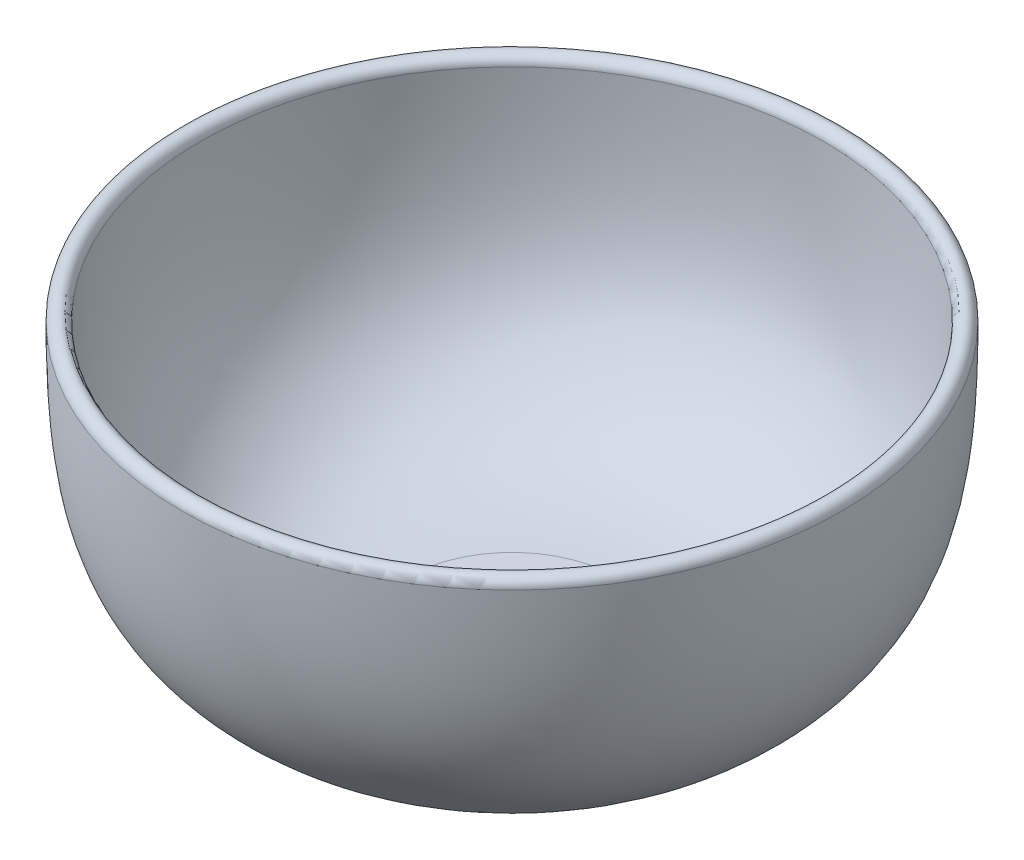
from build123d import *


with BuildPart() as part:
    # Sketch1 → Revolve1 (revolve)
    with BuildSketch(Plane.XY):
        with BuildLine():
            Line((0, -37.46), (-30, -37.46))
            add(Edge.make_bspline(
                [(-30, -37.46), (-30.860987655, -37.46), (-32.606384875, -37.436114905), (-35.907865784, -37.296406862), (-39.817777832, -36.956148055), (-44.141638766, -36.304452803), (-49.459131211, -35.139355309), (-55.314542104, -33.180371267), (-61.260272929, -30.180937219), (-66.306097048, -26.674863401), (-70.628017093, -22.778750971), (-74.360513918, -18.663243679), (-78.553686947, -12.892201761), (-81.720452029, -6.463840501), (-84.038098793, 1.011931752), (-85.383465168, 7.233798397), (-86.367922337, 14.152286295), (-86.914872267, 20.561245493), (-87.20606829, 26.11179732), (-87.355926733, 30.493774797), (-87.427627432, 34.341265749), (-87.455492262, 37.528398326), (-87.46, 39.181053667), (-87.46, 40)],
                knots=[0, 0, 0, 0, 0.015625, 0.03125, 0.0625, 0.09375, 0.125, 0.1875, 0.25, 0.3125, 0.375, 0.4375, 0.5, 0.625, 0.6875, 0.75, 0.8125, 0.875, 0.90625, 0.9375, 0.96875, 0.984375, 1, 1, 1, 1], degree=3))
            ThreePointArc((-87.46, 40), (-90, 42.54), (-92.54, 40))
            add(Edge.make_bspline(
                [(-30, -42.54), (-30.907962003, -42.54), (-32.746038976, -42.514860457), (-36.242922485, -42.36704185), (-40.40837206, -42.005035786), (-45.056419158, -41.305173118), (-50.822831183, -40.042688364), (-57.257038116, -37.893825348), (-63.863155421, -34.56359119), (-69.478379985, -30.659863783), (-74.227877463, -26.37528178), (-78.297070737, -21.888977199), (-82.953169481, -15.487752611), (-86.458114171, -8.353479458), (-88.963406512, -0.257946307), (-90.392057601, 6.359644466), (-91.420131492, 13.597402216), (-91.983690219, 20.211984523), (-92.281742104, 25.895480325), (-92.434438696, 30.362824064), (-92.50721601, 34.270368364), (-92.535442498, 37.500107851), (-92.54, 39.171401362), (-92.54, 40)],
                knots=[0, 0, 0, 0, 0.015625, 0.03125, 0.0625, 0.09375, 0.125, 0.1875, 0.25, 0.3125, 0.375, 0.4375, 0.5, 0.625, 0.6875, 0.75, 0.8125, 0.875, 0.90625, 0.9375, 0.96875, 0.984375, 1, 1, 1, 1], degree=3))
            Line((-30, -42.54), (0, -42.54))
            Line((0, -42.54), (0, -37.46))
        make_face()
    revolve(axis=Axis((0, -40, 0), (0, 1, 0)))


solid = part.part
